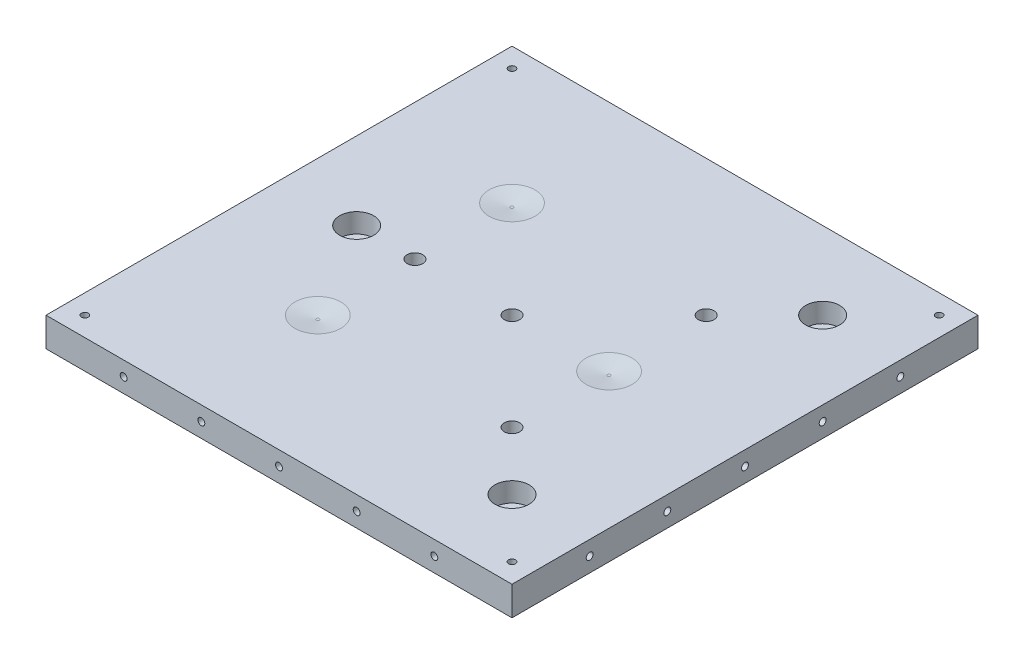
from build123d import *

# Parameters (mm, degrees)
PLATES_DIMS_W                                    = 152.4
PLATES_DIMS_H                                    = 152.4
PLATE_THICKNESS_DEPTH                            = 9.525
F_4_40_TAPPED_HOLE1_D                            = 2.2606
LPATTERN1_COUNT                                  = 2
LPATTERN1_PITCH                                  = 139.7
LPATTERN1_COUNT_DIR2                             = 2
LPATTERN1_PITCH_DIR2                             = 139.7
LPATTERN3_COUNT                                  = 5
LPATTERN3_PITCH                                  = 25.4
LPATTERN4_COUNT                                  = 5
LPATTERN4_PITCH                                  = 25.4
BOTTOM_CONE_R                                    = 8.89
TOP_CONE_R                                       = 0.5
BOTTOM_GROOVE_W                                  = 17.78
BOTTOM_GROOVE_H                                  = 23.8125
TOP_GROOVE_W                                     = 1
TOP_GROOVE_H                                     = 23.8125
FLAT_DIMS_W                                      = 19.05
FLAT_DIMS_H                                      = 19.05
FLAT_CUT_LENGTH_DEPTH                            = 4.7112
F_1_4_20_TAPPED_HOLE2_D                          = 5.1054
CBORE_FOR_1_4_SOCKET_HEAD_CAP_SCREW1_D           = 6.7564
CBORE_FOR_1_4_SOCKET_HEAD_CAP_SCREW1_CBORE_D     = 11.1125
CBORE_FOR_1_4_SOCKET_HEAD_CAP_SCREW1_CBORE_DEPTH = 6.35
REST_TOP_CIRCLE_X_R                              = 7.5
REST_BOTTOM_CIRCLE_X_R                           = 0.5
REST_BOTTOM_CIRCLE_X_Z_R                         = 0.5
REST_TOP_CIRCLE_X_Z_R                            = 7.5
REST_BOTTOM_CIRCLE_X_Z_2_R                       = 0.5
REST_TOP_CIRCLE_X_Z_2_R                          = 7.5


with BuildPart() as part:
    # Plates_Dims → Plate_Thickness (new body)
    with BuildSketch(Plane(origin=(0, 0, 0), x_dir=(1, 0, 0), z_dir=(0, 1, 0))):
        Rectangle(PLATES_DIMS_W, PLATES_DIMS_H)
    extrude(amount=PLATE_THICKNESS_DEPTH)

    # #4-40 Tapped Hole1 (through all)
    with Locations(Plane(origin=(69.85, 9.525, 69.85), x_dir=(0, 0, 1), z_dir=(0, 1, 0))):
        with Locations((0, 0)):
            f_4_40_tapped_hole1 = Hole(F_4_40_TAPPED_HOLE1_D / 2)

    # LPattern1: 4-40 Tapped Hole1 2 × 2
    with Locations(*[(-j * LPATTERN1_PITCH_DIR2, 0, -i * LPATTERN1_PITCH) for i in range(LPATTERN1_COUNT) for j in range(LPATTERN1_COUNT_DIR2) if (i, j) != (0, 0)]):
        add(f_4_40_tapped_hole1, mode=Mode.SUBTRACT)

    # Sketch5 → #4-40 Tapped Hole3 (revolve, cut)
    with BuildSketch(Plane(origin=(-50.8, 4.7625, 76.2), x_dir=(0, -1, 0), z_dir=(1, 0, 0))):
        Polygon((0, 0), (0, 8.279152758), (1.1303, 7.6), (1.1303, 0), align=None)
    f_4_40_tapped_hole3 = revolve(axis=Axis((-50.8, 4.7625, 82.55), (0, 0, -1)), mode=Mode.SUBTRACT)

    # LPattern3: #4-40 Tapped Hole3 ×5
    with Locations(*[(i * LPATTERN3_PITCH, 0, 0) for i in range(1, LPATTERN3_COUNT)]):
        add(f_4_40_tapped_hole3, mode=Mode.SUBTRACT)

    # Sketch6 → #4-40 Tapped Hole4 (revolve, cut)
    with BuildSketch(Plane(origin=(-76.2, 4.7625, -50.8), x_dir=(0, 0, 1), z_dir=(0, 1, 0))):
        Polygon((0, 0), (0, 8.279152758), (1.1303, 7.6), (1.1303, 0), align=None)
    f_4_40_tapped_hole4 = revolve(axis=Axis((-82.55, 4.7625, -50.8), (1, 0, 0)), mode=Mode.SUBTRACT)

    # LPattern4: #4-40 Tapped Hole4 ×5
    with Locations(*[(0, 0, i * LPATTERN4_PITCH) for i in range(1, LPATTERN4_COUNT)]):
        add(f_4_40_tapped_hole4, mode=Mode.SUBTRACT)

    # Mirrior_Y: #4-40 Tapped Hole3 across plane
    add(f_4_40_tapped_hole3.mirror(Plane(origin=(0, 0, 0), x_dir=(1, 0, 0), z_dir=(0, 0, -1))), mode=Mode.SUBTRACT)

    # Mirrior_Y copy 1 sketch → Mirrior_Y copy 1 (revolve, cut)
    with BuildSketch(Plane(origin=(-25.4, 4.7625, -76.2), x_dir=(0, -1, 0), z_dir=(1, 0, 0))):
        Polygon((0, 0), (0, -8.279152758), (1.1303, -7.6), (1.1303, 0), align=None)
    revolve(axis=Axis((-25.4, 4.7625, -82.55), (0, 0, -1)), mode=Mode.SUBTRACT)

    # Mirrior_Y copy 2 sketch → Mirrior_Y copy 2 (revolve, cut)
    with BuildSketch(Plane(origin=(0, 4.7625, -76.2), x_dir=(0, -1, 0), z_dir=(1, 0, 0))):
        Polygon((0, 0), (0, -8.279152758), (1.1303, -7.6), (1.1303, 0), align=None)
    revolve(axis=Axis((0, 4.7625, -82.55), (0, 0, -1)), mode=Mode.SUBTRACT)

    # Mirrior_Y copy 3 sketch → Mirrior_Y copy 3 (revolve, cut)
    with BuildSketch(Plane(origin=(25.4, 4.7625, -76.2), x_dir=(0, -1, 0), z_dir=(1, 0, 0))):
        Polygon((0, 0), (0, -8.279152758), (1.1303, -7.6), (1.1303, 0), align=None)
    revolve(axis=Axis((25.4, 4.7625, -82.55), (0, 0, -1)), mode=Mode.SUBTRACT)

    # Mirrior_Y copy 4 sketch → Mirrior_Y copy 4 (revolve, cut)
    with BuildSketch(Plane(origin=(50.8, 4.7625, -76.2), x_dir=(0, -1, 0), z_dir=(1, 0, 0))):
        Polygon((0, 0), (0, -8.279152758), (1.1303, -7.6), (1.1303, 0), align=None)
    revolve(axis=Axis((50.8, 4.7625, -82.55), (0, 0, -1)), mode=Mode.SUBTRACT)

    # Mirror_X: #4-40 Tapped Hole4 across plane
    add(f_4_40_tapped_hole4.mirror(Plane.ZY), mode=Mode.SUBTRACT)

    # Mirror_X copy 1 sketch → Mirror_X copy 1 (revolve, cut)
    with BuildSketch(Plane(origin=(76.2, 4.7625, -25.4), x_dir=(0, 0, 1), z_dir=(0, 1, 0))):
        Polygon((0, 0), (0, -8.279152758), (1.1303, -7.6), (1.1303, 0), align=None)
    revolve(axis=Axis((82.55, 4.7625, -25.4), (1, 0, 0)), mode=Mode.SUBTRACT)

    # Mirror_X copy 2 sketch → Mirror_X copy 2 (revolve, cut)
    with BuildSketch(Plane(origin=(76.2, 4.7625, 0), x_dir=(0, 0, 1), z_dir=(0, 1, 0))):
        Polygon((0, 0), (0, -8.279152758), (1.1303, -7.6), (1.1303, 0), align=None)
    revolve(axis=Axis((82.55, 4.7625, 0), (1, 0, 0)), mode=Mode.SUBTRACT)

    # Mirror_X copy 3 sketch → Mirror_X copy 3 (revolve, cut)
    with BuildSketch(Plane(origin=(76.2, 4.7625, 25.4), x_dir=(0, 0, 1), z_dir=(0, 1, 0))):
        Polygon((0, 0), (0, -8.279152758), (1.1303, -7.6), (1.1303, 0), align=None)
    revolve(axis=Axis((82.55, 4.7625, 25.4), (1, 0, 0)), mode=Mode.SUBTRACT)

    # Mirror_X copy 4 sketch → Mirror_X copy 4 (revolve, cut)
    with BuildSketch(Plane(origin=(76.2, 4.7625, 50.8), x_dir=(0, 0, 1), z_dir=(0, 1, 0))):
        Polygon((0, 0), (0, -8.279152758), (1.1303, -7.6), (1.1303, 0), align=None)
    revolve(axis=Axis((82.55, 4.7625, 50.8), (1, 0, 0)), mode=Mode.SUBTRACT)

    # Bottom_Cone → Cone_Cut section 0
    with BuildSketch(Plane(origin=(0, 0, 0), x_dir=(1, 0, 0), z_dir=(0, 1, 0))):
        with Locations((-50.8, -50.8)):
            Circle(BOTTOM_CONE_R)
    # Top_Cone → Cone_Cut section 1
    with BuildSketch(Plane(origin=(0, 6.35, 0), x_dir=(-1, 0, 0), z_dir=(0, -1, 0))):
        with Locations((50.8, -50.8)):
            Circle(TOP_CONE_R)
    loft(mode=Mode.SUBTRACT)

    # Bottom_Groove → Groove_Cut section 0
    with BuildSketch(Plane(origin=(0, 0, 0), x_dir=(1, 0, 0), z_dir=(0, 1, 0))):
        with Locations((-50.8, 50.8)):
            Rectangle(BOTTOM_GROOVE_W, BOTTOM_GROOVE_H)
    # Top_Groove → Groove_Cut section 1
    with BuildSketch(Plane(origin=(0, 6.35, 0), x_dir=(-1, 0, 0), z_dir=(0, -1, 0))):
        with Locations((50.8, 50.8)):
            Rectangle(TOP_GROOVE_W, TOP_GROOVE_H)
    loft(mode=Mode.SUBTRACT)

    # Flat_Dims → Flat_Cut_Length (cut)
    with BuildSketch(Plane(origin=(0, 0, 0), x_dir=(1, 0, 0), z_dir=(0, 1, 0))):
        with Locations((50.8, 0)):
            Rectangle(FLAT_DIMS_W, FLAT_DIMS_H)
    extrude(amount=FLAT_CUT_LENGTH_DEPTH, mode=Mode.SUBTRACT)

    # 1/4-20 Tapped Hole2 (through all)
    with Locations(Plane(origin=(-31.75, 9.525, 0), x_dir=(0, 0, 1), z_dir=(0, 1, 0))):
        with Locations((0, 0), (0, 31.75), (31.75, 63.5), (-31.75, 63.5)):
            Hole(F_1_4_20_TAPPED_HOLE2_D / 2)

    # CBORE for 1/4 Socket Head Cap Screw1 (through all)
    with Locations(Plane(origin=(-50.8, 9.525, 0), x_dir=(0, 0, 1), z_dir=(0, 1, 0))):
        with Locations((0, 0), (50.8, 101.6), (-50.8, 101.6)):
            CounterBoreHole(CBORE_FOR_1_4_SOCKET_HEAD_CAP_SCREW1_D / 2, CBORE_FOR_1_4_SOCKET_HEAD_CAP_SCREW1_CBORE_D / 2, CBORE_FOR_1_4_SOCKET_HEAD_CAP_SCREW1_CBORE_DEPTH)

    # Rest_Top_Circle_X → Cut-Loft8 section 0
    with BuildSketch(Plane(origin=(0, 9.525, 0), x_dir=(1, 0, 0), z_dir=(0, 1, 0))):
        with Locations((31.75, 0)):
            Circle(REST_TOP_CIRCLE_X_R)
    # Rest_Bottom_Circle_X → Cut-Loft8 section 1
    with BuildSketch(Plane(origin=(0, 8.35, 0), x_dir=(-1, 0, 0), z_dir=(0, -1, 0))):
        with Locations((-31.75, 0)):
            Circle(REST_BOTTOM_CIRCLE_X_R)
    loft(mode=Mode.SUBTRACT)

    # Rest_Bottom_Circle_X-Z → Cut-Loft9 section 0
    with BuildSketch(Plane(origin=(0, 8.35, 0), x_dir=(-1, 0, 0), z_dir=(0, -1, 0))):
        with Locations((31.75, -31.75)):
            Circle(REST_BOTTOM_CIRCLE_X_Z_R)
    # Rest_Top_Circle_X-Z → Cut-Loft9 section 1
    with BuildSketch(Plane(origin=(0, 9.525, 0), x_dir=(1, 0, 0), z_dir=(0, 1, 0))):
        with Locations((-31.75, -31.75)):
            Circle(REST_TOP_CIRCLE_X_Z_R)
    loft(mode=Mode.SUBTRACT)

    # Rest_Bottom_Circle_X-Z 2 → Cut-Loft10 section 0
    with BuildSketch(Plane(origin=(0, 8.35, 0), x_dir=(-1, 0, 0), z_dir=(0, -1, 0))):
        with Locations((31.75, 31.75)):
            Circle(REST_BOTTOM_CIRCLE_X_Z_2_R)
    # Rest_Top_Circle_X-Z 2 → Cut-Loft10 section 1
    with BuildSketch(Plane(origin=(0, 9.525, 0), x_dir=(1, 0, 0), z_dir=(0, 1, 0))):
        with Locations((-31.75, 31.75)):
            Circle(REST_TOP_CIRCLE_X_Z_2_R)
    loft(mode=Mode.SUBTRACT)


solid = part.part
